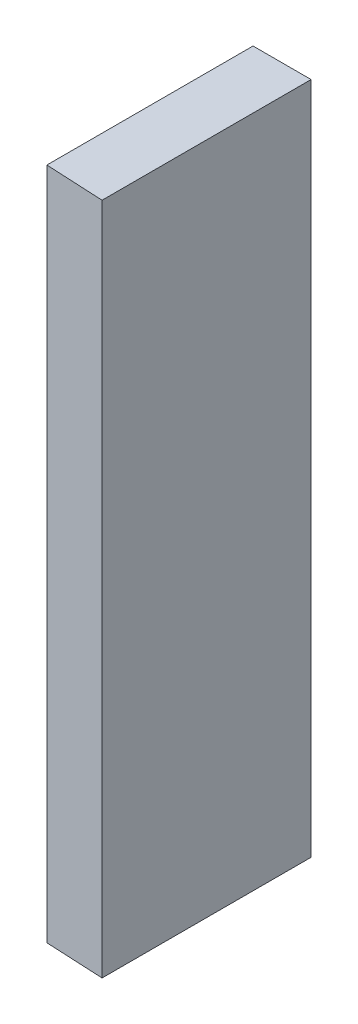
from build123d import *

# Parameters (mm, degrees)
ESQUISSE1_W             = 5
ESQUISSE1_H             = 58
BOSS_EXTRU_1_DEPTH      = 18
ESQUISSE2_W             = 3
ESQUISSE2_H             = 47.75
BOSS_EXTRU_2_DEPTH      = 10
ESQUISSE3_R             = 1.625
ENL_V_MAT_EXTRU_1_DEPTH = 4
ENL_V_MAT_EXTRU_2_DEPTH = 59


with BuildPart() as part:
    # Esquisse1 → Boss.-Extru.1 (new body)
    with BuildSketch(Plane.XY):
        with Locations((2.5, -29)):
            Rectangle(ESQUISSE1_W, ESQUISSE1_H)
    extrude(amount=BOSS_EXTRU_1_DEPTH)

    # Esquisse2 → Boss.-Extru.2 (add)
    with BuildSketch(Plane.ZY):
        with Locations((1.5, -34.125)):
            Rectangle(ESQUISSE2_W, ESQUISSE2_H)
    extrude(amount=BOSS_EXTRU_2_DEPTH)

    # Esquisse3 → Enlèv. mat.-Extru.1 (cut, through all)
    with BuildSketch(Plane.XY.offset(3)):
        with Locations((-5, -15)):
            Circle(ESQUISSE3_R)
        with Locations((-5, -43)):
            Circle(ESQUISSE3_R)
    extrude(amount=-ENL_V_MAT_EXTRU_1_DEPTH, mode=Mode.SUBTRACT)

    # Esquisse4 → Enlèv. mat.-Extru.2 (cut, through all)
    with BuildSketch(Plane.XZ.offset(58)):
        Polygon((0, 18), (0, 17.75), (5, 18), align=None)
    extrude(amount=-ENL_V_MAT_EXTRU_2_DEPTH, mode=Mode.SUBTRACT)


solid = part.part
